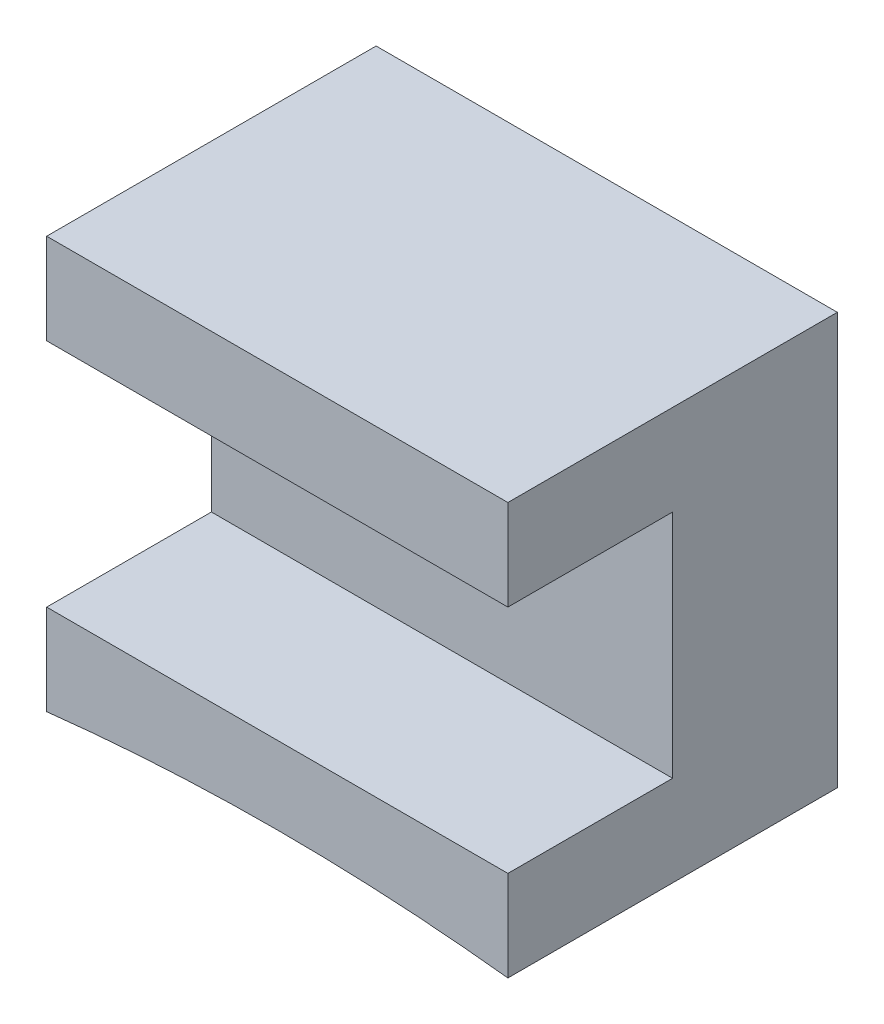
from build123d import *

# Parameters (mm, degrees)
BOSS_EXTRUDE1_DEPTH = 5.08
SKETCH2_W           = 7.112
SKETCH2_H           = 3.556
CUT_EXTRUDE1_DEPTH  = 2.54


with BuildPart() as part:
    # Sketch1 → Boss-Extrude1 (new body)
    with BuildSketch(Plane.XY):
        with BuildLine():
            Line((-3.556, -0.199764438), (-3.556, 6.150235562))
            Line((-3.556, 6.150235562), (3.556, 6.150235562))
            Line((3.556, 6.150235562), (3.556, -0.199764438))
            ThreePointArc((3.556, -0.199764438), (0, 0), (-3.556, -0.199764438))
        make_face()
    extrude(amount=BOSS_EXTRUDE1_DEPTH)

    # Sketch2 → Cut-Extrude1 (cut)
    with BuildSketch(Plane.XY.offset(5.08)):
        with Locations((0, 2.975235562)):
            Rectangle(SKETCH2_W, SKETCH2_H)
    extrude(amount=-CUT_EXTRUDE1_DEPTH, mode=Mode.SUBTRACT)


solid = part.part
